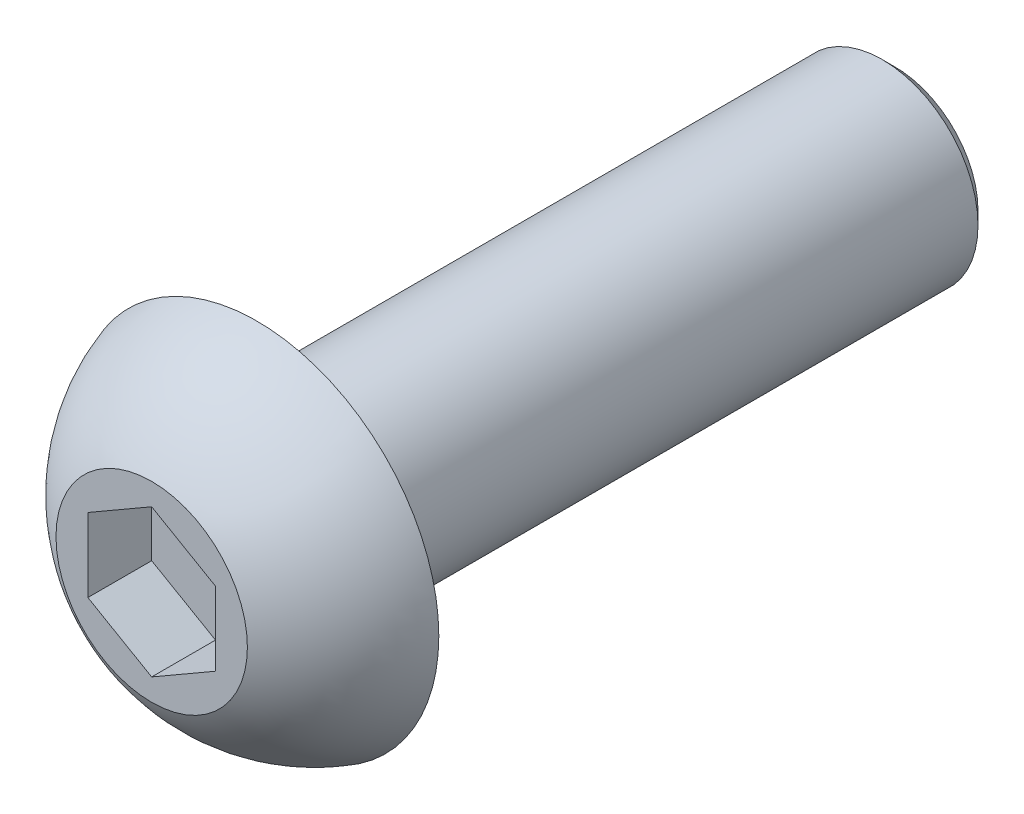
from build123d import *

# Parameters (mm, degrees)
CORTAR_EXTRUIR2_DEPTH = 1
CHAFL_N1_SIZE         = 0.2


with BuildPart() as part:
    # Croquis1 → Revolución1 (revolve)
    with BuildSketch(Plane(origin=(0, 0, 0), x_dir=(0, 0, -1), z_dir=(1, 0, 0))):
        with BuildLine():
            Line((0, 2.85), (0, 1.5))
            Line((0, 1.5), (10, 1.5))
            Line((10, 1.5), (10, 0))
            Line((10, 0), (-1.65, 0))
            Line((-1.65, 0), (-1.65, 1.5))
            ThreePointArc((-1.65, 1.5), (-0.955984269, 2.335091885), (0, 2.85))
        make_face()
    revolve(axis=Axis((0, 0, -10), (0, 0, -1)))

    # Croquis2 → Cortar-Extruir2 (cut)
    with BuildSketch(Plane.XY.offset(1.65)):
        Polygon((0, 1.154700538), (-1, 0.577350269), (-1, -0.577350269), (0, -1.154700538), (1, -0.577350269), (1, 0.577350269), align=None)
    extrude(amount=-CORTAR_EXTRUIR2_DEPTH, mode=Mode.SUBTRACT)

    # Chaflán1
    chafl_n1_edges = [part.edges().sort_by_distance(p)[0] for p in [
        (0, -1.5, -10),
    ]]
    chamfer(chafl_n1_edges, length=CHAFL_N1_SIZE)


solid = part.part
